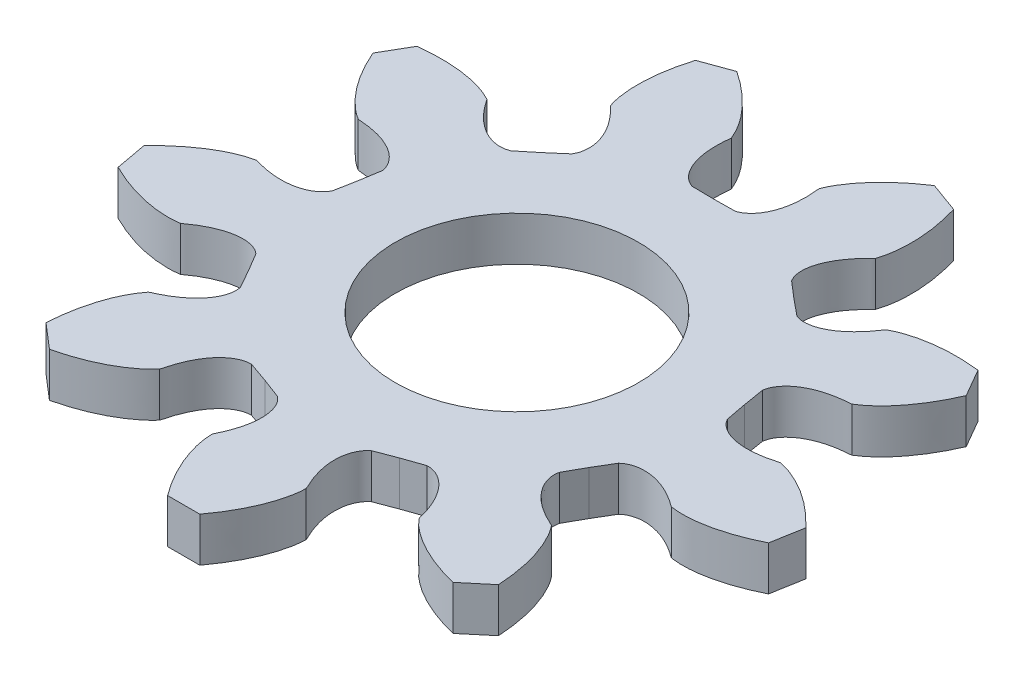
from build123d import *

# Parameters (mm, degrees)
ESBO_O1_R                = 11
RESSALTO_EXTRUS_O1_DEPTH = 4


with BuildPart() as part:
    # Esboço1 → Ressalto-extrusão1 (new body)
    with BuildSketch(Plane(origin=(0, 0, 0), x_dir=(1, 0, 0), z_dir=(0, 1, 0))):
        with BuildLine():
            Line((-20.489513651, -22.086851384), (-18.249347994, -24.015107882))
            add(Edge.make_bspline(
                [(-18.249347994, -24.015107882), (-17.037056034, -23.725855669), (-15.245963886, -23.119519185), (-13.083666009, -21.865281254), (-12.128955388, -21.060469164), (-11.722657071, -20.593912409)],
                knots=[0.006618391, 0.006618391, 0.006618391, 0.006618391, 0.502213764, 0.750011451, 0.997809138, 0.997809138, 0.997809138, 0.997809138], degree=3))
            add(Edge.make_bspline(
                [(-11.722657071, -20.593912409), (-11.675729834, -20.478403511), (-11.623508286, -20.238612514), (-11.481387298, -19.726838673), (-11.182305796, -18.858172842), (-10.585072487, -17.680245233), (-9.68661297, -16.668202446), (-8.86785228, -16.217058925), (-8.332803929, -16.063929501), (-8.065850288, -16.059283754), (-7.931949119, -16.055386416)],
                knots=[0.002675924, 0.002675924, 0.002675924, 0.002675924, 0.065194125, 0.127712326, 0.252748729, 0.502821534, 0.75289434, 0.877930742, 0.940448944, 1.002967145, 1.002967145, 1.002967145, 1.002967145], degree=3))
            Line((-7.931949119, -16.055386416), (-6.079405861, -16.703028479))
            Line((-6.079405861, -16.703028479), (-4.243978962, -17.397697885))
            add(Edge.make_bspline(
                [(-4.243978962, -17.397697885), (-4.143909887, -17.486753442), (-3.942397783, -17.661906791), (-3.630956633, -18.123133212), (-3.29373918, -18.995018462), (-3.256007772, -20.347806898), (-3.555657969, -21.634045971), (-3.884915839, -22.491728375), (-4.105006856, -22.975123605), (-4.219137482, -23.19238147), (-4.257436786, -23.31103066)],
                knots=[-0.002967145, -0.002967145, -0.002967145, -0.002967145, 0.059551056, 0.122069258, 0.247105661, 0.497178468, 0.747251275, 0.872287679, 0.93480588, 0.997324082, 0.997324082, 0.997324082, 0.997324082], degree=3))
            add(Edge.make_bspline(
                [(-4.257436786, -23.31103066), (-4.24609139, -23.929597386), (-4.032063613, -25.159795349), (-3.181856363, -27.510495705), (-2.199545582, -29.126268185), (-1.456803987, -30.127094631)],
                knots=[0.002190857, 0.002190857, 0.002190857, 0.002190857, 0.249988545, 0.497786233, 0.993381608, 0.993381608, 0.993381608, 0.993381608], degree=3))
            Line((-1.456803987, -30.127094631), (1.456802171, -30.127094631))
            add(Edge.make_bspline(
                [(1.456802171, -30.127094631), (2.199543951, -29.12626833), (3.181854559, -27.510495795), (4.032062231, -25.159795513), (4.246089757, -23.929597526), (4.257435424, -23.311030793)],
                knots=[0.006618391, 0.006618391, 0.006618391, 0.006618391, 0.502213764, 0.750011451, 0.997809138, 0.997809138, 0.997809138, 0.997809138], degree=3))
            add(Edge.make_bspline(
                [(4.257435424, -23.311030793), (4.219136084, -23.192381597), (4.10500543, -22.975123672), (3.884914538, -22.491728555), (3.555656628, -21.634046039), (3.256006613, -20.347806968), (3.293737969, -18.99501857), (3.630955581, -18.123133355), (3.9423967, -17.66190696), (4.143908826, -17.486753619), (4.243977911, -17.397698072)],
                knots=[0.002675924, 0.002675924, 0.002675924, 0.002675924, 0.065194125, 0.127712326, 0.252748729, 0.502821534, 0.75289434, 0.877930742, 0.940448944, 1.002967145, 1.002967145, 1.002967145, 1.002967145], degree=3))
            Line((4.243977911, -17.397698072), (6.079404673, -16.703028823))
            Line((6.079404673, -16.703028823), (7.931948137, -16.055386792))
            add(Edge.make_bspline(
                [(7.931948137, -16.055386792), (8.065849304, -16.059284146), (8.332802934, -16.063929912), (8.867851326, -16.217059335), (9.686611917, -16.668202986), (10.585071498, -17.680245769), (11.182304669, -18.858173497), (11.481386129, -19.726839215), (11.623507093, -20.238613224), (11.675728625, -20.478404157), (11.722655886, -20.593913027)],
                knots=[-0.002967145, -0.002967145, -0.002967145, -0.002967145, 0.059551056, 0.122069258, 0.247105661, 0.497178468, 0.747251275, 0.872287679, 0.93480588, 0.997324082, 0.997324082, 0.997324082, 0.997324082], degree=3))
            add(Edge.make_bspline(
                [(11.722655886, -20.593913027), (12.12895399, -21.060469951), (13.083664788, -21.865281861), (15.24596239, -23.119520119), (17.037054636, -23.725856451), (18.249346546, -24.015108894)],
                knots=[0.002190857, 0.002190857, 0.002190857, 0.002190857, 0.249988545, 0.497786233, 0.993381608, 0.993381608, 0.993381608, 0.993381608], degree=3))
            Line((18.249346546, -24.015108894), (20.481298409, -22.142279024))
            add(Edge.make_bspline(
                [(20.481298409, -22.142279024), (20.406952877, -20.898176383), (20.120847894, -19.029005724), (19.261143741, -16.681761879), (18.634342315, -15.601801305), (18.245426568, -15.120658842)],
                knots=[0.006618391, 0.006618391, 0.006618391, 0.006618391, 0.502213764, 0.750011451, 0.997809138, 0.997809138, 0.997809138, 0.997809138], degree=3))
            add(Edge.make_bspline(
                [(18.245426568, -15.120658842), (18.139821338, -15.054386626), (17.912741482, -14.96131917), (17.433421686, -14.732488725), (16.629887799, -14.287108705), (15.573564032, -13.494403729), (14.732912308, -12.433854445), (14.430798972, -11.549192319), (14.372906099, -10.99568191), (14.414686945, -10.731977169), (14.43410051, -10.599433494)],
                knots=[0.002675924, 0.002675924, 0.002675924, 0.002675924, 0.065194125, 0.127712326, 0.252748729, 0.502821534, 0.75289434, 0.877930742, 0.940448944, 1.002967145, 1.002967145, 1.002967145, 1.002967145], degree=3))
            Line((14.43410051, -10.599433494), (15.393594195, -8.887496395))
            Line((15.393594195, -8.887496395), (16.396428549, -7.200581831))
            add(Edge.make_bspline(
                [(16.396428549, -7.200581831), (16.501507965, -7.117497365), (16.70899255, -6.949461743), (17.217293093, -6.72284321), (18.134489644, -6.542150133), (19.473278174, -6.739901197), (20.687942675, -7.258352106), (21.475419926, -7.731542795), (21.913252892, -8.032230836), (22.107391547, -8.182353993), (22.217587585, -8.24067466)],
                knots=[-0.002967145, -0.002967145, -0.002967145, -0.002967145, 0.059551056, 0.122069258, 0.247105661, 0.497178468, 0.747251275, 0.872287679, 0.93480588, 0.997324082, 0.997324082, 0.997324082, 0.997324082], degree=3))
            add(Edge.make_bspline(
                [(22.217587585, -8.24067466), (22.828727, -8.336914611), (24.077401025, -8.339760032), (26.5400259, -7.910664172), (28.301827643, -7.223852847), (29.416425011, -6.666186854)],
                knots=[0.002190857, 0.002190857, 0.002190857, 0.002190857, 0.249988545, 0.497786233, 0.993381608, 0.993381608, 0.993381608, 0.993381608], degree=3))
            Line((29.416425011, -6.666186854), (29.922367497, -3.796845024))
            add(Edge.make_bspline(
                [(29.922367497, -3.796845024), (29.065721753, -2.891595497), (27.645072881, -1.643632438), (25.477722031, -0.398146511), (24.303379006, 0.026251095), (23.696179845, 0.144837381)],
                knots=[0.006618391, 0.006618391, 0.006618391, 0.006618391, 0.502213764, 0.750011451, 0.997809138, 0.997809138, 0.997809138, 0.997809138], degree=3))
            add(Edge.make_bspline(
                [(23.696179845, 0.144837381), (23.572682587, 0.127723111), (23.338906718, 0.053052801), (22.824637076, -0.079753734), (21.922809648, -0.255074471), (20.60407776, -0.326819059), (19.278393239, -0.054751686), (18.478311143, 0.428744111), (18.078172997, 0.815544863), (17.940672842, 1.044410625), (17.870347063, 1.158423769)],
                knots=[0.002675924, 0.002675924, 0.002675924, 0.002675924, 0.065194125, 0.127712326, 0.252748729, 0.502821534, 0.75289434, 0.877930742, 0.940448944, 1.002967145, 1.002967145, 1.002967145, 1.002967145], degree=3))
            Line((17.870347063, 1.158423769), (17.504949913, 3.086594323))
            Line((17.504949913, 3.086594323), (17.188837817, 5.023455348))
            add(Edge.make_bspline(
                [(17.188837817, 5.023455348), (17.215927655, 5.154645488), (17.266858852, 5.416736763), (17.510572074, 5.917065922), (18.097038123, 6.645047428), (19.249721571, 7.354118004), (20.513462383, 7.737732857), (21.420866067, 7.881428379), (21.949544125, 7.932521582), (22.194760268, 7.942310494), (22.316663133, 7.968466919)],
                knots=[-0.002967145, -0.002967145, -0.002967145, -0.002967145, 0.059551056, 0.122069258, 0.247105661, 0.497178468, 0.747251275, 0.872287679, 0.93480588, 0.997324082, 0.997324082, 0.997324082, 0.997324082], degree=3))
            add(Edge.make_bspline(
                [(22.316663133, 7.968466919), (22.846684934, 8.287575683), (23.805053733, 9.088028156), (25.415716332, 10.999679411), (26.323860957, 12.658271742), (26.819231286, 13.801918054)],
                knots=[0.002190857, 0.002190857, 0.002190857, 0.002190857, 0.249988545, 0.497786233, 0.993381608, 0.993381608, 0.993381608, 0.993381608], degree=3))
            Line((26.819231286, 13.801918054), (25.362428283, 16.325175048))
            add(Edge.make_bspline(
                [(25.362428283, 16.325175048), (24.124316392, 16.467995147), (22.233861026, 16.510814821), (19.772991029, 16.071766122), (18.600594558, 15.642020404), (18.059227219, 15.342562673)],
                knots=[0.006618391, 0.006618391, 0.006618391, 0.006618391, 0.502213764, 0.750011451, 0.997809138, 0.997809138, 0.997809138, 0.997809138], degree=3))
            add(Edge.make_bspline(
                [(18.059227219, 15.342562673), (17.975623672, 15.250069873), (17.844538116, 15.042600865), (17.535951111, 14.610299003), (16.957805218, 13.89631203), (15.993714515, 12.99368797), (14.803299718, 12.349970084), (13.879616168, 12.206066494), (13.324461833, 12.245169219), (13.072018527, 12.332107168), (12.944859619, 12.374241764)],
                knots=[0.002675924, 0.002675924, 0.002675924, 0.002675924, 0.065194125, 0.127712326, 0.252748729, 0.502821534, 0.75289434, 0.877930742, 0.940448944, 1.002967145, 1.002967145, 1.002967145, 1.002967145], degree=3))
            Line((12.944859619, 12.374241764), (11.425545021, 13.616433342))
            Line((11.425545021, 13.616433342), (9.938398838, 14.896962029))
            add(Edge.make_bspline(
                [(9.938398838, 14.896962029), (9.874823461, 15.014872518), (9.745369997, 15.248384026), (9.610459773, 15.788314237), (9.591781339, 16.722953534), (10.019006308, 18.007063747), (10.74050506, 19.113246709), (11.343250909, 19.806591711), (11.715399719, 20.18555908), (11.896953992, 20.350679719), (11.973523978, 20.449074354)],
                knots=[-0.002967145, -0.002967145, -0.002967145, -0.002967145, 0.059551056, 0.122069258, 0.247105661, 0.497178468, 0.747251275, 0.872287679, 0.93480588, 0.997324082, 0.997324082, 0.997324082, 0.997324082], degree=3))
            add(Edge.make_bspline(
                [(11.973523978, 20.449074354), (12.174425074, 21.034217296), (12.394057235, 22.263427055), (12.399110628, 24.763150839), (12.028667172, 26.61745039), (11.67302118, 27.811952202)],
                knots=[0.002190857, 0.002190857, 0.002190857, 0.002190857, 0.249988545, 0.497786233, 0.993381608, 0.993381608, 0.993381608, 0.993381608], degree=3))
            Line((11.67302118, 27.811952202), (8.935127004, 28.80846428))
            add(Edge.make_bspline(
                [(8.935127004, 28.80846428), (7.894875279, 28.122027841), (6.419178495, 26.939668328), (4.816257773, 25.021520769), (4.194385194, 23.938714524), (3.972161472, 23.361332376)],
                knots=[0.006618391, 0.006618391, 0.006618391, 0.006618391, 0.502213764, 0.750011451, 0.997809138, 0.997809138, 0.997809138, 0.997809138], degree=3))
            add(Edge.make_bspline(
                [(3.972161472, 23.361332376), (3.967570664, 23.236739456), (4.000511811, 22.993548804), (4.04199873, 22.464030462), (4.058055262, 21.545459693), (3.899714498, 20.234303988), (3.401577739, 18.976003597), (2.786494532, 18.27203471), (2.336086893, 17.945142807), (2.086821464, 17.849473711), (1.962328493, 17.800014513)],
                knots=[0.002675924, 0.002675924, 0.002675924, 0.002675924, 0.065194125, 0.127712326, 0.252748729, 0.502821534, 0.75289434, 0.877930742, 0.940448944, 1.002967145, 1.002967145, 1.002967145, 1.002967145], degree=3))
            Line((1.962328493, 17.800014513), (6.33e-07, 17.77499187))
            Line((6.33e-07, 17.77499187), (-1.962327411, 17.800014614))
            add(Edge.make_bspline(
                [(-1.962327411, 17.800014614), (-2.086820376, 17.849473825), (-2.336085787, 17.945142936), (-2.786493465, 18.272034852), (-3.401576535, 18.976003827), (-3.899713356, 20.234304236), (-4.058053948, 21.545460005), (-4.041997416, 22.464030655), (-4.000510417, 22.993549146), (-3.967569277, 23.236739732), (-3.972160116, 23.361332634)],
                knots=[-0.002967145, -0.002967145, -0.002967145, -0.002967145, 0.059551056, 0.122069258, 0.247105661, 0.497178468, 0.747251275, 0.872287679, 0.93480588, 0.997324082, 0.997324082, 0.997324082, 0.997324082], degree=3))
            add(Edge.make_bspline(
                [(-3.972160116, 23.361332634), (-4.194383581, 23.938714868), (-4.816256388, 25.021521005), (-6.41917674, 26.939668777), (-7.894873667, 28.12202818), (-8.935125267, 28.808464819)],
                knots=[0.002190857, 0.002190857, 0.002190857, 0.002190857, 0.249988545, 0.497786233, 0.993381608, 0.993381608, 0.993381608, 0.993381608], degree=3))
            Line((-8.935125267, 28.808464819), (-11.673019503, 27.811952906))
            add(Edge.make_bspline(
                [(-11.673019503, 27.811952906), (-12.028665719, 26.617451166), (-12.399108995, 24.763151623), (-12.394056023, 22.263427765), (-12.174423618, 21.034218069), (-11.973522774, 20.449075028)],
                knots=[0.006618391, 0.006618391, 0.006618391, 0.006618391, 0.502213764, 0.750011451, 0.997809138, 0.997809138, 0.997809138, 0.997809138], degree=3))
            add(Edge.make_bspline(
                [(-11.973522774, 20.449075028), (-11.896952752, 20.3506804), (-11.715398432, 20.185559714), (-11.343249778, 19.806592407), (-10.740503852, 19.113247313), (-10.019005273, 18.007064291), (-9.591780269, 16.722954132), (-9.610458863, 15.788314814), (-9.745369068, 15.248384638), (-9.874822554, 15.01487313), (-9.938397944, 14.896962646)],
                knots=[0.002675924, 0.002675924, 0.002675924, 0.002675924, 0.065194125, 0.127712326, 0.252748729, 0.502821534, 0.75289434, 0.877930742, 0.940448944, 1.002967145, 1.002967145, 1.002967145, 1.002967145], degree=3))
            Line((-9.938397944, 14.896962646), (-11.425544052, 13.616434155))
            Line((-11.425544052, 13.616434155), (-12.944858855, 12.374242537))
            add(Edge.make_bspline(
                [(-12.944858855, 12.374242537), (-13.072017767, 12.332107955), (-13.324461069, 12.245170028), (-13.879615441, 12.20606729), (-14.803298944, 12.349971034), (-15.9937138, 12.993688894), (-16.957804413, 13.896313114), (-17.535950228, 14.610299995), (-17.844537269, 15.042602022), (-17.975622786, 15.250070976), (-18.059226347, 15.342563741)],
                knots=[-0.002967145, -0.002967145, -0.002967145, -0.002967145, 0.059551056, 0.122069258, 0.247105661, 0.497178468, 0.747251275, 0.872287679, 0.93480588, 0.997324082, 0.997324082, 0.997324082, 0.997324082], degree=3))
            add(Edge.make_bspline(
                [(-18.059226347, 15.342563741), (-18.600593544, 15.642021704), (-19.77299012, 16.071767193), (-22.23385997, 16.510816293), (-24.124315375, 16.467996443), (-25.362427299, 16.325176576)],
                knots=[0.002190857, 0.002190857, 0.002190857, 0.002190857, 0.249988545, 0.497786233, 0.993381608, 0.993381608, 0.993381608, 0.993381608], degree=3))
            Line((-25.362427299, 16.325176576), (-26.819230454, 13.801919671))
            add(Edge.make_bspline(
                [(-26.819230454, 13.801919671), (-26.323860343, 12.658273271), (-25.415715585, 10.999681062), (-23.80505326, 9.088029479), (-22.846684315, 8.287577211), (-22.316662643, 7.968468208)],
                knots=[0.006618391, 0.006618391, 0.006618391, 0.006618391, 0.502213764, 0.750011451, 0.997809138, 0.997809138, 0.997809138, 0.997809138], degree=3))
            add(Edge.make_bspline(
                [(-22.316662643, 7.968468208), (-22.194759756, 7.942311812), (-21.949543546, 7.932522895), (-21.420865649, 7.88142964), (-20.513461846, 7.737734096), (-19.249721128, 7.354119086), (-18.097037688, 6.645048574), (-17.510571748, 5.917066949), (-17.266858533, 5.41673783), (-17.215927353, 5.154646539), (-17.18883753, 5.023456396)],
                knots=[0.002675924, 0.002675924, 0.002675924, 0.002675924, 0.065194125, 0.127712326, 0.252748729, 0.502821534, 0.75289434, 0.877930742, 0.940448944, 1.002967145, 1.002967145, 1.002967145, 1.002967145], degree=3))
            Line((-17.18883753, 5.023456396), (-17.504949694, 3.086595569))
            Line((-17.504949694, 3.086595569), (-17.870346975, 1.158424852))
            add(Edge.make_bspline(
                [(-17.870346975, 1.158424852), (-17.940672766, 1.044411716), (-18.078172932, 0.815545974), (-18.478311098, 0.428745187), (-19.278393256, -0.05475046), (-20.604077806, -0.32681789), (-21.922809728, -0.255073123), (-22.824637038, -0.079752407), (-23.338906812, 0.053054232), (-23.572682617, 0.127724525), (-23.696179864, 0.144838761)],
                knots=[-0.002967145, -0.002967145, -0.002967145, -0.002967145, 0.059551056, 0.122069258, 0.247105661, 0.497178468, 0.747251275, 0.872287679, 0.93480588, 0.997324082, 0.997324082, 0.997324082, 0.997324082], degree=3))
            add(Edge.make_bspline(
                [(-23.696179864, 0.144838761), (-24.303379065, 0.026252742), (-25.477722023, -0.398145106), (-27.645073018, -1.643630631), (-29.065721807, -2.891593851), (-29.922367726, -3.79684322)],
                knots=[0.002190857, 0.002190857, 0.002190857, 0.002190857, 0.249988545, 0.497786233, 0.993381608, 0.993381608, 0.993381608, 0.993381608], degree=3))
            Line((-29.922367726, -3.79684322), (-29.399123885, -6.656775216))
            add(Edge.make_bspline(
                [(-29.399123885, -6.656775216), (-28.284465764, -7.214455233), (-26.522588412, -7.901333218), (-24.059851442, -8.330440179), (-22.811115561, -8.327589121), (-22.199947983, -8.231337534)],
                knots=[0.006571384, 0.006571384, 0.006571384, 0.006571384, 0.502190261, 0.749999699, 0.997809138, 0.997809138, 0.997809138, 0.997809138], degree=3))
            add(Edge.make_bspline(
                [(-22.199947983, -8.231337534), (-22.090098857, -8.173200431), (-21.899021618, -8.019957354), (-21.460760224, -7.722724968), (-20.675430752, -7.251900514), (-19.462966119, -6.737400495), (-18.127656862, -6.542800973), (-17.214563582, -6.723689072), (-16.707956113, -6.950213324), (-16.501183664, -7.117753225), (-16.396429002, -7.200580932)],
                knots=[0.005880985, 0.005880985, 0.005880985, 0.005880985, 0.06819887, 0.130516755, 0.255152525, 0.504424065, 0.753695605, 0.878331375, 0.94064926, 1.002967145, 1.002967145, 1.002967145, 1.002967145], degree=3))
            Line((-16.396429002, -7.200580932), (-15.393594828, -8.887495387))
            Line((-15.393594828, -8.887495387), (-14.459220223, -10.554614997))
            add(Edge.make_bspline(
                [(-14.459220223, -10.554614997), (-14.439866671, -10.686749049), (-14.398159106, -10.949589185), (-14.455287075, -11.501586287), (-14.755180172, -12.382792241), (-15.591362907, -13.441904273), (-16.643165446, -14.234679332), (-17.443576023, -14.679382293), (-17.920117672, -14.910311635), (-18.148368638, -14.999167792), (-18.253641377, -15.065231393)],
                knots=[-0.002967145, -0.002967145, -0.002967145, -0.002967145, 0.05935074, 0.121668625, 0.246304395, 0.495575936, 0.744847477, 0.869483247, 0.931801133, 0.994119018, 0.994119018, 0.994119018, 0.994119018], degree=3))
            add(Edge.make_bspline(
                [(-18.253641377, -15.065231393), (-18.642557327, -15.546373676), (-19.269358546, -16.626334393), (-20.129063068, -18.973578024), (-20.415167884, -20.842748752), (-20.489513651, -22.086851384)],
                knots=[0.002190857, 0.002190857, 0.002190857, 0.002190857, 0.249988545, 0.497786233, 0.993381608, 0.993381608, 0.993381608, 0.993381608], degree=3))
        make_face()
        Circle(ESBO_O1_R, mode=Mode.SUBTRACT)
    extrude(amount=RESSALTO_EXTRUS_O1_DEPTH)


solid = part.part
